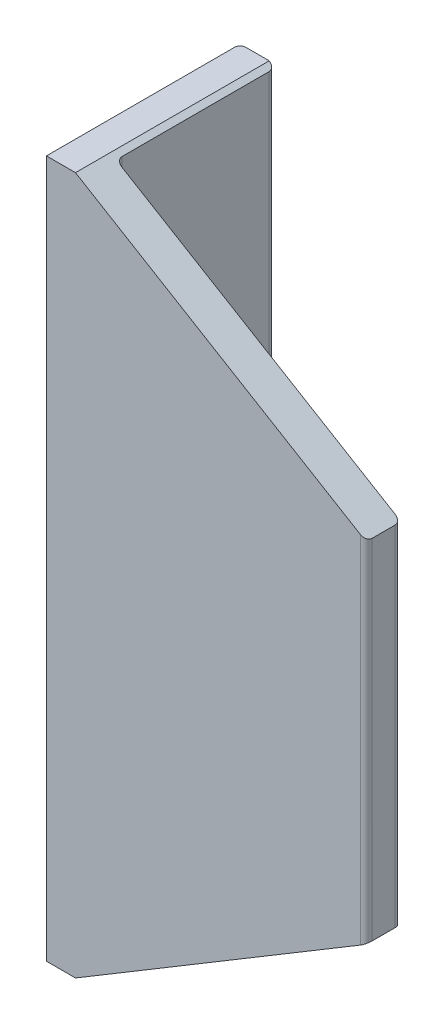
from build123d import *

# Parameters (mm, degrees)
BOSS_EXTRUDE1_DEPTH = 120
RIB6_REACH          = 89.955
SKETCH4_WALL_W      = 232.65925255
SKETCH4_WALL_H      = 6
CUT_EXTRUDE1_DEPTH  = 137.147387456
SCALE3_SCALE        = 7.5


with BuildPart() as part:
    # Sketch1 → Boss-Extrude1 (new body)
    with BuildSketch(Plane(origin=(0, 0, 0), x_dir=(1, 0, 0), z_dir=(0, 1, 0))):
        with BuildLine():
            Line((0, 0), (0, 32.333333333))
            ThreePointArc((0, 32.333333333), (0.292893219, 33.040440115), (1, 33.333333333))
            Line((1, 33.333333333), (5, 33.333333333))
            ThreePointArc((5, 33.333333333), (5.707106781, 33.040440115), (6, 32.333333333))
            Line((6, 32.333333333), (6, 7))
            ThreePointArc((6, 7), (6.292893219, 6.292893219), (7, 6))
            Line((7, 6), (54, 6))
            ThreePointArc((54, 6), (54.707106781, 5.707106781), (55, 5))
            Line((55, 5), (55, 1))
            ThreePointArc((55, 1), (54.707106781, 0.292893219), (54, 0))
            Line((54, 0), (0, 0))
        make_face()
    extrude(amount=BOSS_EXTRUDE1_DEPTH)

    # Sketch4 wall → Rib6 (add, up to next)
    with BuildSketch(Plane(origin=(30, 60, -19.166666666), x_dir=(0.876729593434, 0, 0.480983596392), z_dir=(0.480983596392, 0, -0.876729593434)), mode=Mode.PRIVATE) as rib6_sk1:
        Rectangle(SKETCH4_WALL_W, SKETCH4_WALL_H)
    rib6_tool1 = extrude(rib6_sk1.sketch, amount=-RIB6_REACH, mode=Mode.PRIVATE) - part.part
    add(rib6_tool1.solids().sort_by_distance((30, 60, -19.166666666))[0])

    # Sketch5 → Cut-Extrude1 (cut, through all)
    with BuildSketch(Plane.XY):
        Polygon((55, 120), (5, 120), (55, 90), align=None)
        Polygon((55, 30), (55, 0), (5, 0), align=None)
    extrude(amount=-CUT_EXTRUDE1_DEPTH, mode=Mode.SUBTRACT)


with BuildPart() as part_1:
    # Scale3: scaled about (16.387200979, 60, -9.868580773)
    add(part.part.scale(SCALE3_SCALE).moved(Location((-106.516806363, -390, 64.145775024))))


solid = part_1.part
